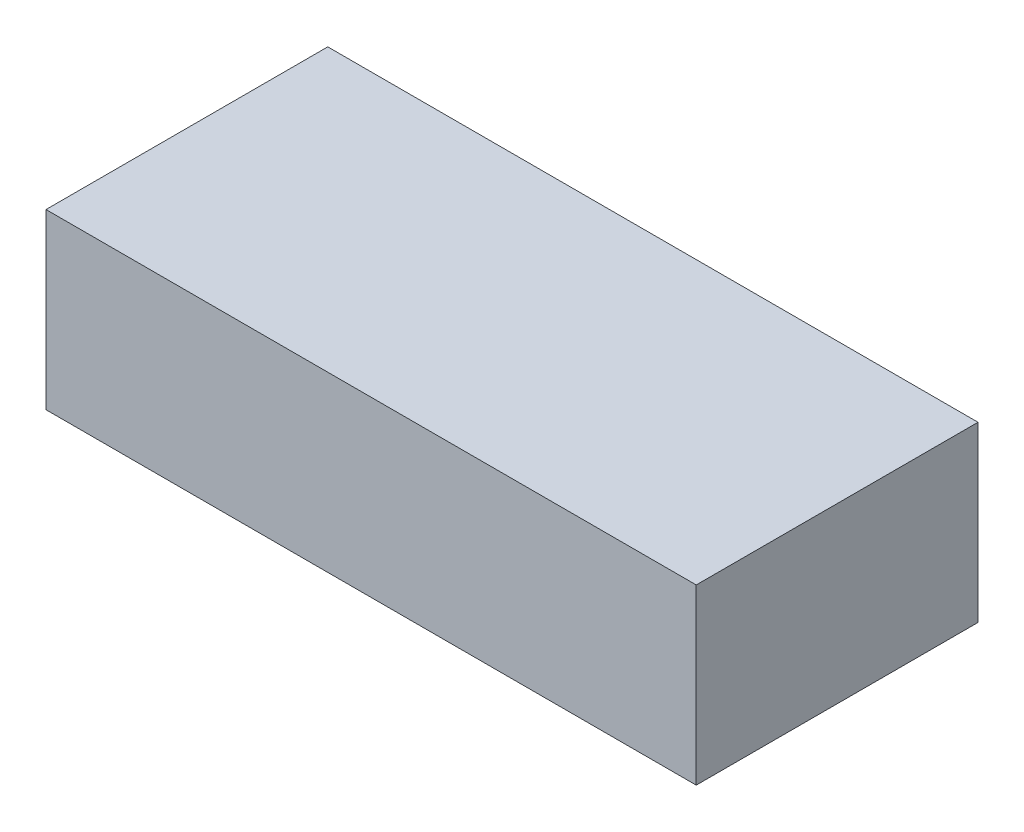
from build123d import *

# Parameters (mm, degrees)
SKETCH1_W           = 150
SKETCH1_H           = 65
BOSS_EXTRUDE1_DEPTH = 40
SKETCH2_W           = 143.904
SKETCH2_H           = 58.904
CUT_EXTRUDE1_DEPTH  = 28.4
SKETCH3_R           = 4.33
CUT_EXTRUDE2_DEPTH  = 3.048


with BuildPart() as part:
    # Sketch1 → Boss-Extrude1 (new body)
    with BuildSketch(Plane(origin=(0, 0, 0), x_dir=(1, 0, 0), z_dir=(0, 1, 0))):
        Rectangle(SKETCH1_W, SKETCH1_H)
    extrude(amount=BOSS_EXTRUDE1_DEPTH)

    # Sketch2 → Cut-Extrude1 (cut)
    with BuildSketch(Plane.XZ):
        Rectangle(SKETCH2_W, SKETCH2_H)
    extrude(amount=-CUT_EXTRUDE1_DEPTH, mode=Mode.SUBTRACT)

    # Sketch3 → Cut-Extrude2 (cut)
    with BuildSketch(Plane(origin=(0, 0, -32.5), x_dir=(-1, 0, 0), z_dir=(0, 0, -1))):
        with Locations((38.12, 12.19)):
            Circle(SKETCH3_R)
    extrude(amount=-CUT_EXTRUDE2_DEPTH, mode=Mode.SUBTRACT)


solid = part.part
